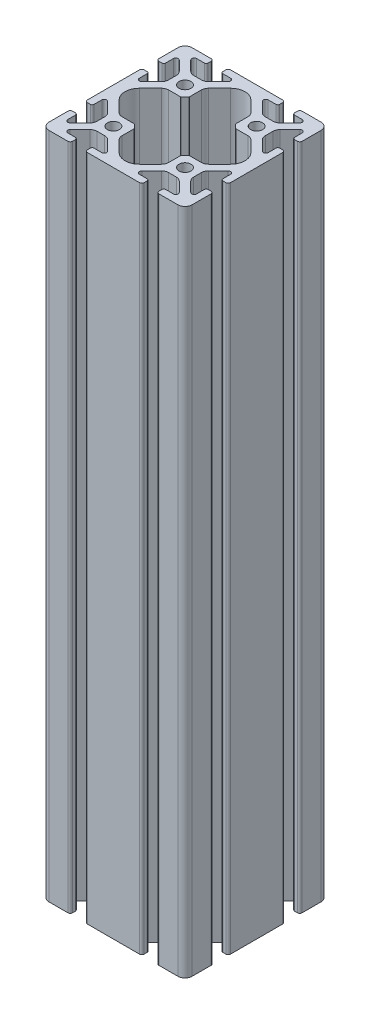
from build123d import *

# Parameters (mm, degrees)
SCHIZZO1_R                   = 2.5
ESTRUSIONE_ESTRUSIONE1_DEPTH = 280


with BuildPart() as part:
    # Schizzo1 → Estrusione-Estrusione1 (new body)
    with BuildSketch(Plane.XZ.offset(10)):
        with BuildLine():
            Line((11.9, 27.8), (11.9, 29))
            ThreePointArc((11.9, 29), (11.607106781, 29.707106781), (10.9, 30))
            Line((10.9, 30), (-10.9, 30))
            ThreePointArc((-10.9, 30), (-11.607106781, 29.707106781), (-11.9, 29))
            Line((-11.9, 29), (-11.9, 27.8))
            ThreePointArc((-11.9, 27.8), (-11.665685425, 27.234314575), (-11.1, 27))
            Line((-11.1, 27), (-7.872361109, 27))
            ThreePointArc((-7.872361109, 27), (-6.927822606, 26.36887955), (-7.149442636, 25.25472042))
            Line((-7.149442636, 25.25472042), (-11.275483397, 21.128679659))
            ThreePointArc((-11.275483397, 21.128679659), (-12.248753443, 20.478361405), (-13.39680374, 20.250000003))
            Line((-13.39680374, 20.250000003), (-16.603196261, 20.250000003))
            ThreePointArc((-16.603196261, 20.250000003), (-17.751246557, 20.478361405), (-18.724516603, 21.128679659))
            Line((-18.724516603, 21.128679659), (-22.850557363, 25.254720419))
            ThreePointArc((-22.850557363, 25.254720419), (-23.072177393, 26.368879549), (-22.12763889, 27))
            Line((-22.12763889, 27), (-18.9, 27))
            ThreePointArc((-18.9, 27), (-18.334314575, 27.234314575), (-18.1, 27.8))
            Line((-18.1, 27.8), (-18.1, 29))
            ThreePointArc((-18.1, 29), (-18.392893219, 29.707106781), (-19.1, 30))
            Line((-19.1, 30), (-27, 30))
            ThreePointArc((-27, 30), (-29.121320344, 29.121320344), (-30, 27))
            Line((-30, 27), (-30, 19.1))
            ThreePointArc((-30, 19.1), (-29.707106781, 18.392893219), (-29, 18.1))
            Line((-29, 18.1), (-27.8, 18.1))
            ThreePointArc((-27.8, 18.1), (-27.234314575, 18.334314575), (-27, 18.9))
            Line((-27, 18.9), (-27, 22.12763889))
            ThreePointArc((-27, 22.12763889), (-26.36887955, 23.072177392), (-25.254720421, 22.850557362))
            Line((-25.254720421, 22.850557362), (-21.128679659, 18.7245166))
            ThreePointArc((-21.128679659, 18.7245166), (-20.478361405, 17.751246554), (-20.250000003, 16.603196257))
            Line((-20.250000003, 16.603196257), (-20.250000003, 13.396803739))
            ThreePointArc((-20.250000003, 13.396803739), (-20.478361405, 12.248753443), (-21.128679659, 11.275483397))
            Line((-21.128679659, 11.275483397), (-25.254720419, 7.149442637))
            ThreePointArc((-25.254720419, 7.149442637), (-26.36887955, 6.927822607), (-27, 7.87236111))
            Line((-27, 7.87236111), (-27, 11.1))
            ThreePointArc((-27, 11.1), (-27.234314575, 11.665685425), (-27.8, 11.9))
            Line((-27.8, 11.9), (-29, 11.9))
            ThreePointArc((-29, 11.9), (-29.707106781, 11.607106781), (-30, 10.9))
            Line((-30, 10.9), (-30, -10.9))
            ThreePointArc((-30, -10.9), (-29.707106781, -11.607106781), (-29, -11.9))
            Line((-29, -11.9), (-27.8, -11.9))
            ThreePointArc((-27.8, -11.9), (-27.234314575, -11.665685425), (-27, -11.1))
            Line((-27, -11.1), (-27, -7.87236111))
            ThreePointArc((-27, -7.87236111), (-26.36887955, -6.927822608), (-25.254720421, -7.149442638))
            Line((-25.254720421, -7.149442638), (-21.128679659, -11.2754834))
            ThreePointArc((-21.128679659, -11.2754834), (-20.478361405, -12.248753446), (-20.250000003, -13.396803743))
            Line((-20.250000003, -13.396803743), (-20.250000003, -16.603196261))
            ThreePointArc((-20.250000003, -16.603196261), (-20.478361405, -17.751246557), (-21.128679659, -18.724516603))
            Line((-21.128679659, -18.724516603), (-25.254720419, -22.850557363))
            ThreePointArc((-25.254720419, -22.850557363), (-26.36887955, -23.072177393), (-27, -22.12763889))
            Line((-27, -22.12763889), (-27, -18.9))
            ThreePointArc((-27, -18.9), (-27.234314575, -18.334314575), (-27.8, -18.1))
            Line((-27.8, -18.1), (-29, -18.1))
            ThreePointArc((-29, -18.1), (-29.707106781, -18.392893219), (-30, -19.1))
            Line((-30, -19.1), (-30, -27))
            ThreePointArc((-30, -27), (-29.121320344, -29.121320344), (-27, -30))
            Line((-27, -30), (-19.1, -30))
            ThreePointArc((-19.1, -30), (-18.392893219, -29.707106781), (-18.1, -29))
            Line((-18.1, -29), (-18.1, -27.8))
            ThreePointArc((-18.1, -27.8), (-18.334314575, -27.234314575), (-18.9, -27))
            Line((-18.9, -27), (-22.12763889, -27))
            ThreePointArc((-22.12763889, -27), (-23.072177392, -26.36887955), (-22.850557362, -25.254720421))
            Line((-22.850557362, -25.254720421), (-18.724516602, -21.128679661))
            ThreePointArc((-18.724516602, -21.128679661), (-17.751246556, -20.478361407), (-16.603196259, -20.250000005))
            Line((-16.603196259, -20.250000005), (-13.39680374, -20.250000005))
            ThreePointArc((-13.39680374, -20.250000005), (-12.248753444, -20.478361407), (-11.275483399, -21.12867966))
            Line((-11.275483399, -21.12867966), (-7.14944264, -25.254720419))
            ThreePointArc((-7.14944264, -25.254720419), (-6.92782261, -26.36887955), (-7.872361112, -27))
            Line((-7.872361112, -27), (-11.1, -27))
            ThreePointArc((-11.1, -27), (-11.665685425, -27.234314575), (-11.9, -27.8))
            Line((-11.9, -27.8), (-11.9, -29))
            ThreePointArc((-11.9, -29), (-11.607106781, -29.707106781), (-10.9, -30))
            Line((-10.9, -30), (10.9, -30))
            ThreePointArc((10.9, -30), (11.607106781, -29.707106781), (11.9, -29))
            Line((11.9, -29), (11.9, -27.8))
            ThreePointArc((11.9, -27.8), (11.665685425, -27.234314575), (11.1, -27))
            Line((11.1, -27), (7.87236111, -27))
            ThreePointArc((7.87236111, -27), (6.927822608, -26.36887955), (7.149442638, -25.254720421))
            Line((7.149442638, -25.254720421), (11.275483398, -21.128679661))
            ThreePointArc((11.275483398, -21.128679661), (12.248753444, -20.478361407), (13.396803741, -20.250000005))
            Line((13.396803741, -20.250000005), (16.60319626, -20.250000005))
            ThreePointArc((16.60319626, -20.250000005), (17.751246556, -20.478361407), (18.724516601, -21.12867966))
            Line((18.724516601, -21.12867966), (22.85055736, -25.254720419))
            ThreePointArc((22.85055736, -25.254720419), (23.07217739, -26.36887955), (22.127638888, -27))
            Line((22.127638888, -27), (18.9, -27))
            ThreePointArc((18.9, -27), (18.334314575, -27.234314575), (18.1, -27.8))
            Line((18.1, -27.8), (18.1, -29))
            ThreePointArc((18.1, -29), (18.392893219, -29.707106781), (19.1, -30))
            Line((19.1, -30), (27, -30))
            ThreePointArc((27, -30), (29.121320344, -29.121320344), (30, -27))
            Line((30, -27), (30, -19.1))
            ThreePointArc((30, -19.1), (29.707106781, -18.392893219), (29, -18.1))
            Line((29, -18.1), (27.799999997, -18.1))
            ThreePointArc((27.799999997, -18.1), (27.234314572, -18.334314575), (26.999999996, -18.9))
            Line((26.999999996, -18.9), (26.999999996, -22.12763889))
            ThreePointArc((26.999999996, -22.12763889), (26.368879547, -23.072177392), (25.254720417, -22.850557361))
            Line((25.254720417, -22.850557361), (21.128679657, -18.724516601))
            ThreePointArc((21.128679657, -18.724516601), (20.478361404, -17.751246555), (20.250000001, -16.603196259))
            Line((20.250000001, -16.603196259), (20.250000001, -13.396803744))
            ThreePointArc((20.250000001, -13.396803744), (20.478361403, -12.248753448), (21.128679657, -11.275483402))
            Line((21.128679657, -11.275483402), (25.254720417, -7.149442642))
            ThreePointArc((25.254720417, -7.149442642), (26.368879547, -6.927822612), (26.999999996, -7.872361114))
            Line((26.999999996, -7.872361114), (26.999999996, -11.1))
            ThreePointArc((26.999999996, -11.1), (27.234314572, -11.665685425), (27.799999997, -11.9))
            Line((27.799999997, -11.9), (29, -11.9))
            ThreePointArc((29, -11.9), (29.707106781, -11.607106781), (30, -10.9))
            Line((30, -10.9), (30, 10.9))
            ThreePointArc((30, 10.9), (29.707106781, 11.607106781), (29, 11.9))
            Line((29, 11.9), (27.799999997, 11.9))
            ThreePointArc((27.799999997, 11.9), (27.234314572, 11.665685425), (26.999999996, 11.1))
            Line((26.999999996, 11.1), (26.999999996, 7.87236111))
            ThreePointArc((26.999999996, 7.87236111), (26.368879547, 6.927822608), (25.254720417, 7.149442639))
            Line((25.254720417, 7.149442639), (21.128679657, 11.275483399))
            ThreePointArc((21.128679657, 11.275483399), (20.478361404, 12.248753445), (20.250000001, 13.396803741))
            Line((20.250000001, 13.396803741), (20.250000001, 16.603196256))
            ThreePointArc((20.250000001, 16.603196256), (20.478361403, 17.751246552), (21.128679657, 18.724516598))
            Line((21.128679657, 18.724516598), (25.254720417, 22.850557358))
            ThreePointArc((25.254720417, 22.850557358), (26.368879547, 23.072177388), (26.999999996, 22.127638886))
            Line((26.999999996, 22.127638886), (26.999999996, 18.9))
            ThreePointArc((26.999999996, 18.9), (27.234314572, 18.334314575), (27.799999997, 18.1))
            Line((27.799999997, 18.1), (29, 18.1))
            ThreePointArc((29, 18.1), (29.707106781, 18.392893219), (30, 19.1))
            Line((30, 19.1), (30, 27))
            ThreePointArc((30, 27), (29.121320344, 29.121320344), (27, 30))
            Line((27, 30), (19.1, 30))
            ThreePointArc((19.1, 30), (18.392893219, 29.707106781), (18.1, 29))
            Line((18.1, 29), (18.1, 27.8))
            ThreePointArc((18.1, 27.8), (18.334314575, 27.234314575), (18.9, 27))
            Line((18.9, 27), (22.127638891, 27))
            ThreePointArc((22.127638891, 27), (23.072177394, 26.36887955), (22.850557364, 25.25472042))
            Line((22.850557364, 25.25472042), (18.724516603, 21.128679659))
            ThreePointArc((18.724516603, 21.128679659), (17.751246557, 20.478361405), (16.60319626, 20.250000003))
            Line((16.60319626, 20.250000003), (13.396803739, 20.250000003))
            ThreePointArc((13.396803739, 20.250000003), (12.248753443, 20.478361405), (11.275483397, 21.128679659))
            Line((11.275483397, 21.128679659), (7.149442637, 25.254720419))
            ThreePointArc((7.149442637, 25.254720419), (6.927822607, 26.368879549), (7.87236111, 27))
            Line((7.87236111, 27), (11.1, 27))
            ThreePointArc((11.1, 27), (11.665685425, 27.234314575), (11.9, 27.8))
        make_face()
        with Locations((-15, -15)):
            Circle(SCHIZZO1_R, mode=Mode.SUBTRACT)
        with Locations((15, -15)):
            Circle(SCHIZZO1_R, mode=Mode.SUBTRACT)
        with Locations((15, 15)):
            Circle(SCHIZZO1_R, mode=Mode.SUBTRACT)
        with Locations((-15, 15)):
            Circle(SCHIZZO1_R, mode=Mode.SUBTRACT)
        with BuildLine():
            Line((-4.242640695, -23.353196225), (-8.871320331, -18.724516589))
            ThreePointArc((-8.871320331, -18.724516589), (-9.521638584, -17.751246543), (-9.749999987, -16.603196247))
            Line((-9.749999987, -16.603196247), (-9.749999987, -11.670310206))
            ThreePointArc((-9.749999987, -11.670310206), (-9.788060221, -11.47896849), (-9.896446596, -11.316756816))
            Line((-9.896446596, -11.316756816), (-11.316756816, -9.896446596))
            ThreePointArc((-11.316756816, -9.896446596), (-11.47896849, -9.78806022), (-11.670310206, -9.749999986))
            Line((-11.670310206, -9.749999986), (-16.603196246, -9.749999986))
            ThreePointArc((-16.603196246, -9.749999986), (-17.751246544, -9.521638584), (-18.72451659, -8.87132033))
            Line((-18.72451659, -8.87132033), (-23.353196265, -4.242640655))
            ThreePointArc((-23.353196265, -4.242640655), (-25.110555577, 3e-08), (-23.353196265, 4.242640715))
            Line((-23.353196265, 4.242640715), (-18.724516625, 8.871320355))
            ThreePointArc((-18.724516625, 8.871320355), (-17.751246578, 9.521638609), (-16.60319628, 9.750000012))
            Line((-16.60319628, 9.750000012), (-11.67031024, 9.750000012))
            ThreePointArc((-11.67031024, 9.750000012), (-11.478968524, 9.788060246), (-11.31675685, 9.896446621))
            Line((-11.31675685, 9.896446621), (-9.896446596, 11.316756875))
            ThreePointArc((-9.896446596, 11.316756875), (-9.788060221, 11.478968549), (-9.749999987, 11.670310265))
            Line((-9.749999987, 11.670310265), (-9.749999987, 16.603196306))
            ThreePointArc((-9.749999987, 16.603196306), (-9.521638584, 17.751246603), (-8.87132033, 18.72451665))
            Line((-8.87132033, 18.72451665), (-4.24264069, 23.35319629))
            ThreePointArc((-4.24264069, 23.35319629), (-5e-09, 25.110555602), (4.24264068, 23.35319629))
            Line((4.24264068, 23.35319629), (8.87132035, 18.72451662))
            ThreePointArc((8.87132035, 18.72451662), (9.521638604, 17.751246573), (9.750000006, 16.603196276))
            Line((9.750000006, 16.603196276), (9.750000006, 11.670310264))
            ThreePointArc((9.750000006, 11.670310264), (9.78806024, 11.478968547), (9.896446616, 11.316756873))
            Line((9.896446616, 11.316756873), (11.316756868, 9.896446621))
            ThreePointArc((11.316756868, 9.896446621), (11.478968542, 9.788060246), (11.670310258, 9.750000012))
            Line((11.670310258, 9.750000012), (16.603196271, 9.750000012))
            ThreePointArc((16.603196271, 9.750000012), (17.751246568, 9.521638609), (18.724516615, 8.871320355))
            Line((18.724516615, 8.871320355), (23.35319625, 4.24264072))
            ThreePointArc((23.35319625, 4.24264072), (25.110555562, 3.5e-08), (23.35319625, -4.24264065))
            Line((23.35319625, -4.24264065), (18.72451657, -8.87132033))
            ThreePointArc((18.72451657, -8.87132033), (17.751246523, -9.521638584), (16.603196226, -9.749999986))
            Line((16.603196226, -9.749999986), (11.670310187, -9.749999986))
            ThreePointArc((11.670310187, -9.749999986), (11.47896847, -9.78806022), (11.316756796, -9.896446596))
            Line((11.316756796, -9.896446596), (9.896446616, -11.316756776))
            ThreePointArc((9.896446616, -11.316756776), (9.78806024, -11.47896845), (9.750000006, -11.670310166))
            Line((9.750000006, -11.670310166), (9.750000006, -16.603196206))
            ThreePointArc((9.750000006, -16.603196206), (9.521638604, -17.751246504), (8.87132035, -18.72451655))
            Line((8.87132035, -18.72451655), (4.242640675, -23.353196225))
            ThreePointArc((4.242640675, -23.353196225), (-1e-08, -25.110555537), (-4.242640695, -23.353196225))
        make_face(mode=Mode.SUBTRACT)
    extrude(amount=-ESTRUSIONE_ESTRUSIONE1_DEPTH)


solid = part.part
